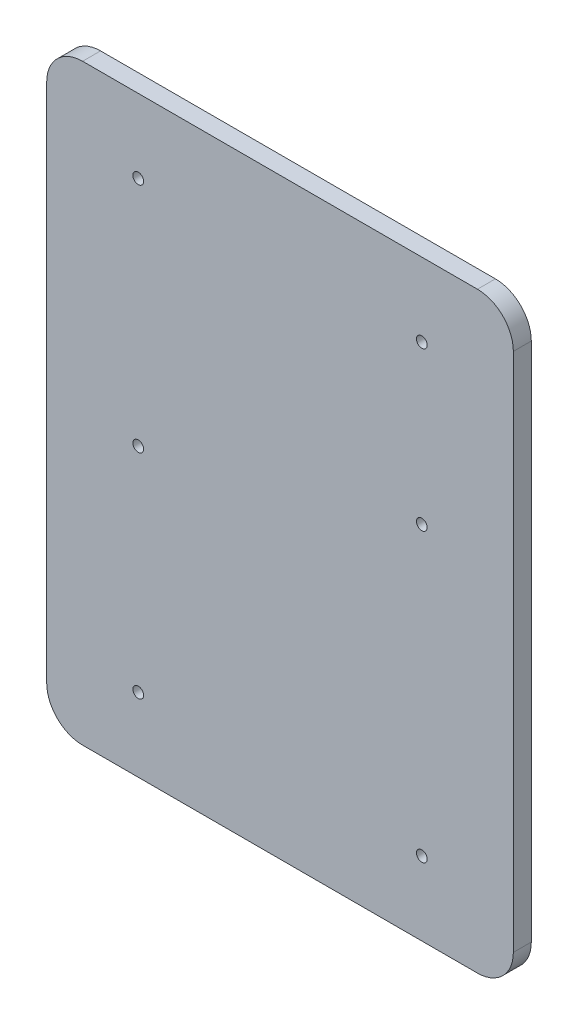
from build123d import *

# Parameters (mm, degrees)
RESSALTO_EXTRUS_O1_DEPTH = 5
ESBO_O2_R                = 1.5
CORTE_EXTRUS_O1_DEPTH    = 5
ESBO_O3_R                = 1.5
CORTE_EXTRUS_O2_DEPTH    = 6
ESBO_O9_R                = 1.5
CORTE_EXTRUS_O7_DEPTH    = 10


with BuildPart() as part:
    # Esboço1 → Ressalto-extrusão1 (new body)
    with BuildSketch(Plane.XY):
        with BuildLine():
            Line((-49.217119449, -36.393854661), (60.782880551, -36.393854661))
            ThreePointArc((60.782880551, -36.393854661), (67.853948363, -33.464922473), (70.782880551, -26.393854661))
            Line((70.782880551, -26.393854661), (70.782880551, 118.606145339))
            ThreePointArc((70.782880551, 118.606145339), (67.853948363, 125.67721315), (60.782880551, 128.606145339))
            Line((60.782880551, 128.606145339), (-49.217119449, 128.606145339))
            ThreePointArc((-49.217119449, 128.606145339), (-56.288187261, 125.67721315), (-59.217119449, 118.606145339))
            Line((-59.217119449, 118.606145339), (-59.217119449, -26.393854661))
            ThreePointArc((-59.217119449, -26.393854661), (-56.288187261, -33.464922473), (-49.217119449, -36.393854661))
        make_face()
    extrude(amount=RESSALTO_EXTRUS_O1_DEPTH)

    # Esboço2 → Corte-extrusão1 (cut)
    with BuildSketch(Plane(origin=(0, 0, 0), x_dir=(-1, 0, 0), z_dir=(0, 0, -1))):
        with Locations((33.717119449, -15.893854661)):
            Circle(ESBO_O2_R)
        with Locations((33.717119449, 108.106145339)):
            Circle(ESBO_O2_R)
        with Locations((-45.282880551, -15.893854661)):
            Circle(ESBO_O2_R)
        with Locations((-45.282880551, 108.106145339)):
            Circle(ESBO_O2_R)
    extrude(amount=-CORTE_EXTRUS_O1_DEPTH, mode=Mode.SUBTRACT)

    # Esboço3 → Corte-extrusão2 (cut, through all)
    with BuildSketch(Plane(origin=(0, 0, 0), x_dir=(-1, 0, 0), z_dir=(0, 0, -1))):
        with Locations((33.717119449, 43.506145339)):
            Circle(ESBO_O3_R)
    extrude(amount=-CORTE_EXTRUS_O2_DEPTH, mode=Mode.SUBTRACT)

    # Esboço9 → Corte-extrusão7 (cut)
    with BuildSketch(Plane(origin=(0, 0, 0), x_dir=(-1, 0, 0), z_dir=(0, 0, -1))):
        with Locations((-45.282880551, 64.106145339)):
            Circle(ESBO_O9_R)
    extrude(amount=-CORTE_EXTRUS_O7_DEPTH, mode=Mode.SUBTRACT)


solid = part.part
